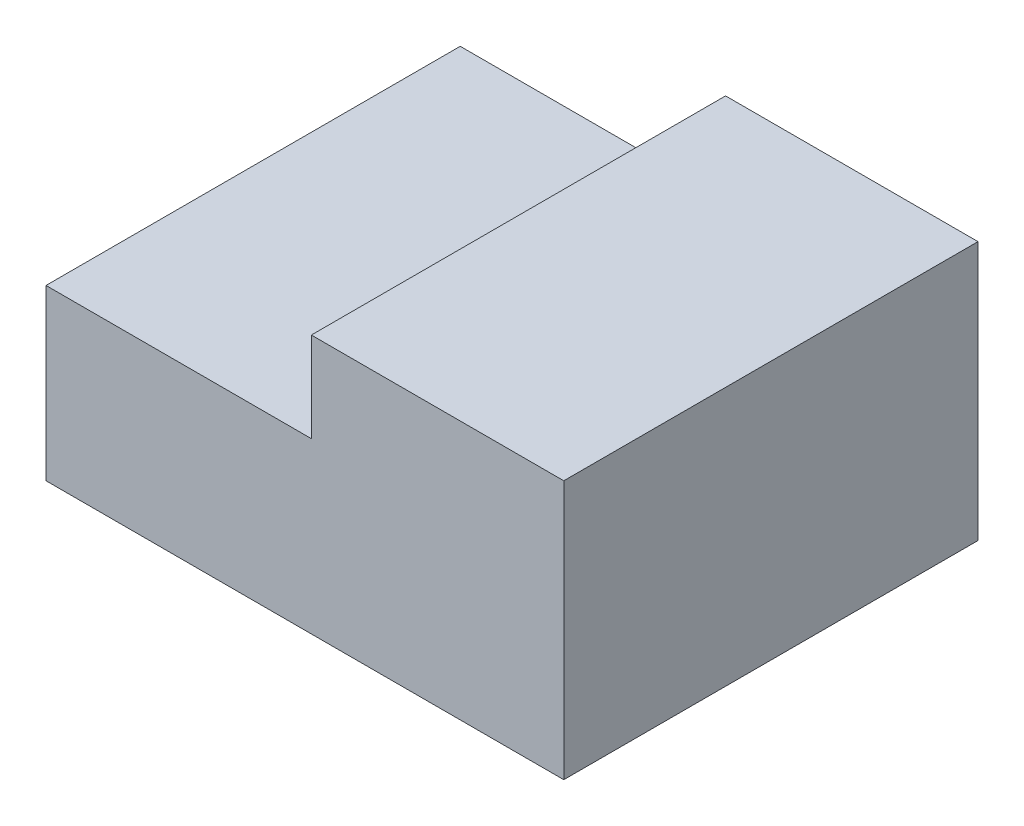
from build123d import *

# Parameters (mm, degrees)
CROQUIS1_W              = 100
CROQUIS1_H              = 50
SALIENTE_EXTRUIR1_DEPTH = 80
CORTAR_EXTRUIR1_DEPTH   = 100


with BuildPart() as part:
    # Croquis1 → Saliente-Extruir1 (new body)
    with BuildSketch(Plane.XY):
        with Locations((-58.081097806, 50.706369262)):
            Rectangle(CROQUIS1_W, CROQUIS1_H)
    extrude(amount=SALIENTE_EXTRUIR1_DEPTH)

    # Croquis2 → Cortar-Extruir1 (cut)
    with BuildSketch(Plane.XY.offset(80)):
        Polygon((-108.081097806, 58.377269755), (-56.833200118, 58.377269755), (-56.833200118, 75.706369262), (-56.833200118, 87.666162545), (-112.181132859, 87.666162545), (-112.181132859, 58.377269755), align=None)
    extrude(amount=-CORTAR_EXTRUIR1_DEPTH, mode=Mode.SUBTRACT)


solid = part.part
